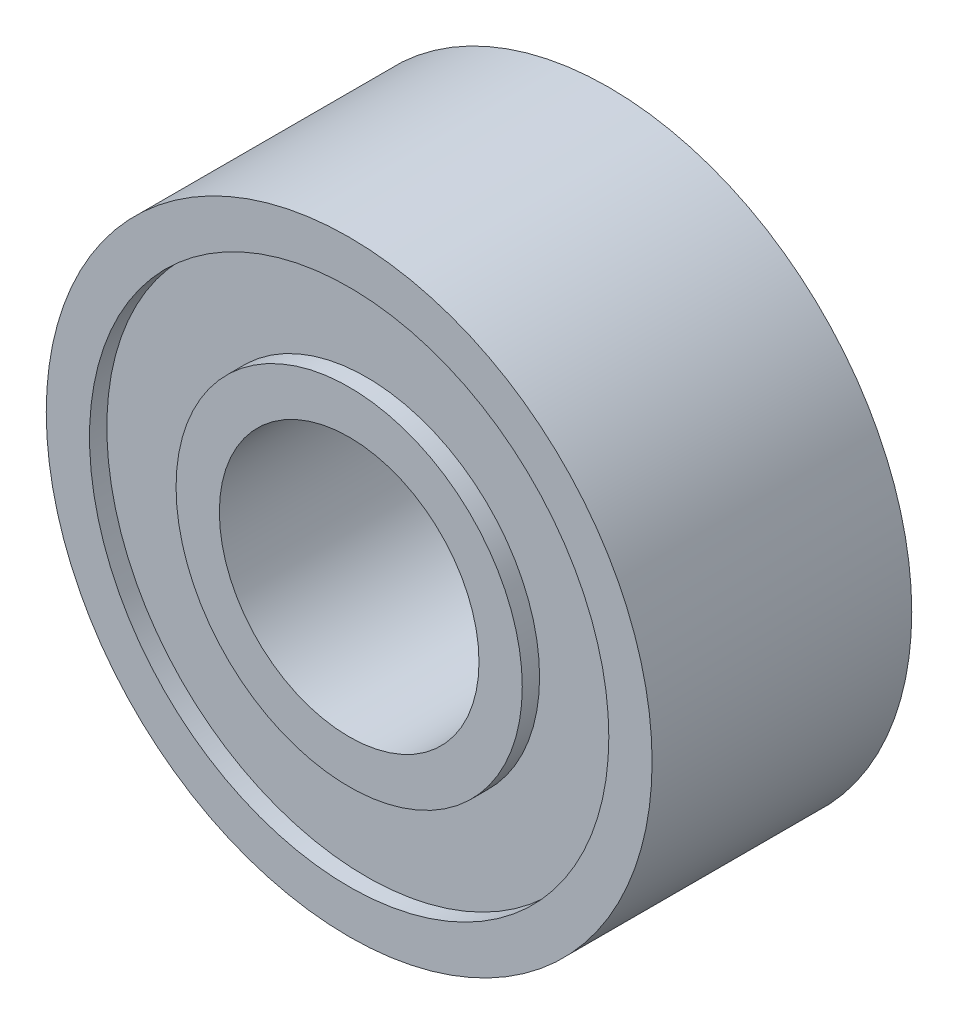
from build123d import *

# Parameters (mm, degrees)
SKETCH1_R           = 3.5
SKETCH1_R_2         = 1.5
BOSS_EXTRUDE1_DEPTH = 3
SKETCH2_R           = 3
SKETCH2_R_2         = 2
CUT_EXTRUDE1_DEPTH  = 3
SKETCH3_R           = 3
SKETCH3_R_2         = 2
BOSS_EXTRUDE3_DEPTH = 2.8
SKETCH4_R           = 3
SKETCH4_R_2         = 2
CUT_EXTRUDE2_DEPTH  = 0.2


with BuildPart() as part:
    # Sketch1 → Boss-Extrude1 (new body)
    with BuildSketch(Plane.XY):
        Circle(SKETCH1_R)
        Circle(SKETCH1_R_2, mode=Mode.SUBTRACT)
    extrude(amount=BOSS_EXTRUDE1_DEPTH)

    # Sketch2 → Cut-Extrude1 (cut)
    with BuildSketch(Plane.XY.offset(3)):
        Circle(SKETCH2_R)
        Circle(SKETCH2_R_2, mode=Mode.SUBTRACT)
    extrude(amount=-CUT_EXTRUDE1_DEPTH, mode=Mode.SUBTRACT)


with BuildPart() as body_2:
    # Sketch3 → Boss-Extrude3 (new body)
    with BuildSketch(Plane.XY.offset(3)):
        Circle(SKETCH3_R)
        Circle(SKETCH3_R_2, mode=Mode.SUBTRACT)
    extrude(amount=-BOSS_EXTRUDE3_DEPTH)

    # Sketch4 → Cut-Extrude2 (cut)
    with BuildSketch(Plane.XY.offset(3)):
        Circle(SKETCH4_R)
        Circle(SKETCH4_R_2, mode=Mode.SUBTRACT)
    extrude(amount=-CUT_EXTRUDE2_DEPTH, mode=Mode.SUBTRACT)


solid = Compound([part.part, body_2.part])
